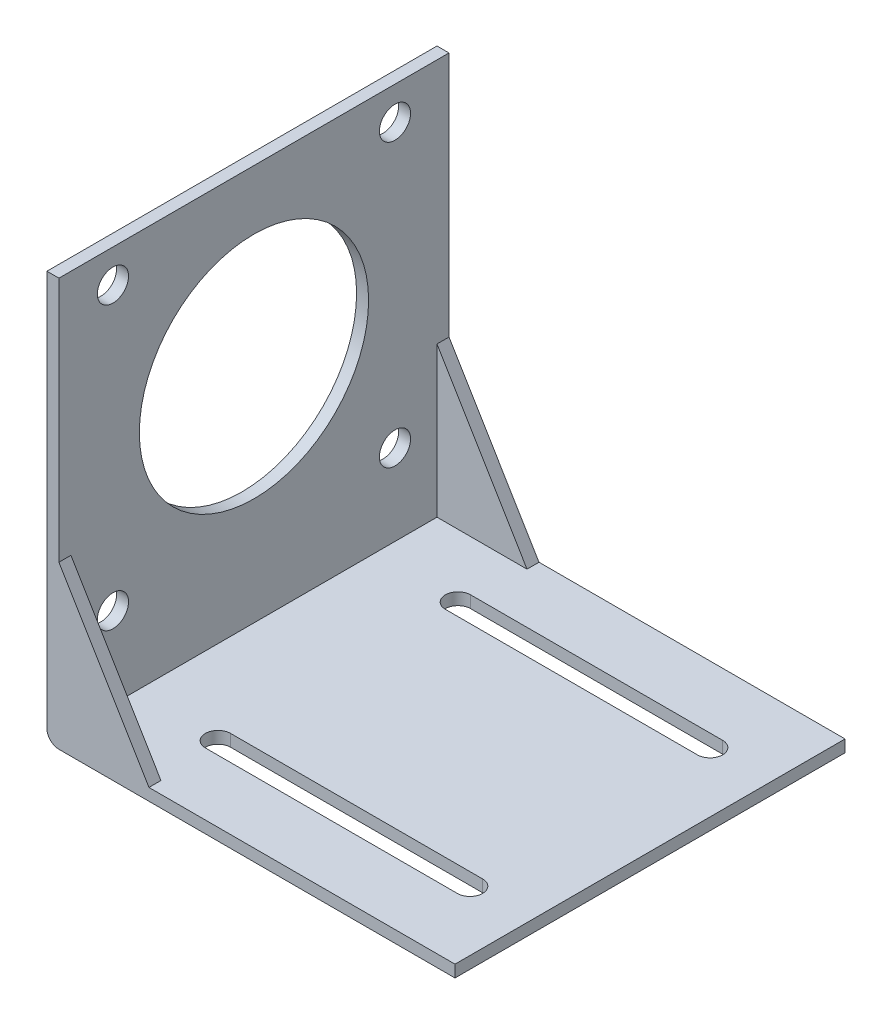
from build123d import *

# Parameters (mm, degrees)
EXTRUDE_1_DEPTH     = 65
SKETCH_2_R          = 19.1
SKETCH_2_R_2        = 2.6
CUT_EXTRUDE_1_DEPTH = 3
CUT_EXTRUDE_2_DEPTH = 3
EXTRUDE_2_DEPTH     = 2
EXTRUDE_3_DEPTH     = 2


with BuildPart() as part:
    # Эскиз1 → Бобышка-Вытянуть1 (new body)
    with BuildSketch(Plane.XY):
        with BuildLine():
            Line((2, 0), (68, 0))
            Line((68, 0), (68, 2))
            Line((68, 2), (2, 2))
            Line((2, 2), (2, 68))
            Line((2, 68), (0, 68))
            Line((0, 68), (0, 2))
            ThreePointArc((0, 2), (0.585786438, 0.585786438), (2, 0))
        make_face()
    extrude(amount=EXTRUDE_1_DEPTH)

    # Эскиз2 → Вырез-Вытянуть1 (cut, through all)
    with BuildSketch(Plane(origin=(2, 0, 0), x_dir=(0, 0, -1), z_dir=(1, 0, 0))):
        with Locations((-32.5, 39)):
            Circle(SKETCH_2_R)
        with Locations((-9, 62.5)):
            Circle(SKETCH_2_R_2)
        with Locations((-9, 15.5)):
            Circle(SKETCH_2_R_2)
        with Locations((-56, 15.5)):
            Circle(SKETCH_2_R_2)
        with Locations((-56, 62.5)):
            Circle(SKETCH_2_R_2)
    extrude(amount=-CUT_EXTRUDE_1_DEPTH, mode=Mode.SUBTRACT)

    # Эскиз3 → Вырез-Вытянуть2 (cut, through all)
    with BuildSketch(Plane(origin=(0, 2, 0), x_dir=(1, 0, 0), z_dir=(0, 1, 0))):
        with BuildLine():
            Line((16, -10.4), (58, -10.4))
            ThreePointArc((58, -10.4), (60.1, -12.5), (58, -14.6))
            Line((58, -14.6), (16, -14.6))
            ThreePointArc((16, -14.6), (13.9, -12.5), (16, -10.4))
        make_face()
        with BuildLine():
            Line((16, -50.4), (58, -50.4))
            ThreePointArc((58, -50.4), (60.1, -52.5), (58, -54.6))
            Line((58, -54.6), (16, -54.6))
            ThreePointArc((16, -54.6), (13.9, -52.5), (16, -50.4))
        make_face()
    extrude(amount=-CUT_EXTRUDE_2_DEPTH, mode=Mode.SUBTRACT)

    # Эскиз4 → Бобышка-Вытянуть2 (add)
    with BuildSketch(Plane.XY.offset(65)):
        Polygon((2, 27), (17, 2), (2, 2), align=None)
    extrude(amount=-EXTRUDE_2_DEPTH)

    # Эскиз5 → Бобышка-Вытянуть3 (add)
    with BuildSketch(Plane(origin=(0, 0, 0), x_dir=(-1, 0, 0), z_dir=(0, 0, -1))):
        Polygon((-2, 27), (-17, 2), (-2, 2), align=None)
    extrude(amount=-EXTRUDE_3_DEPTH)


solid = part.part
